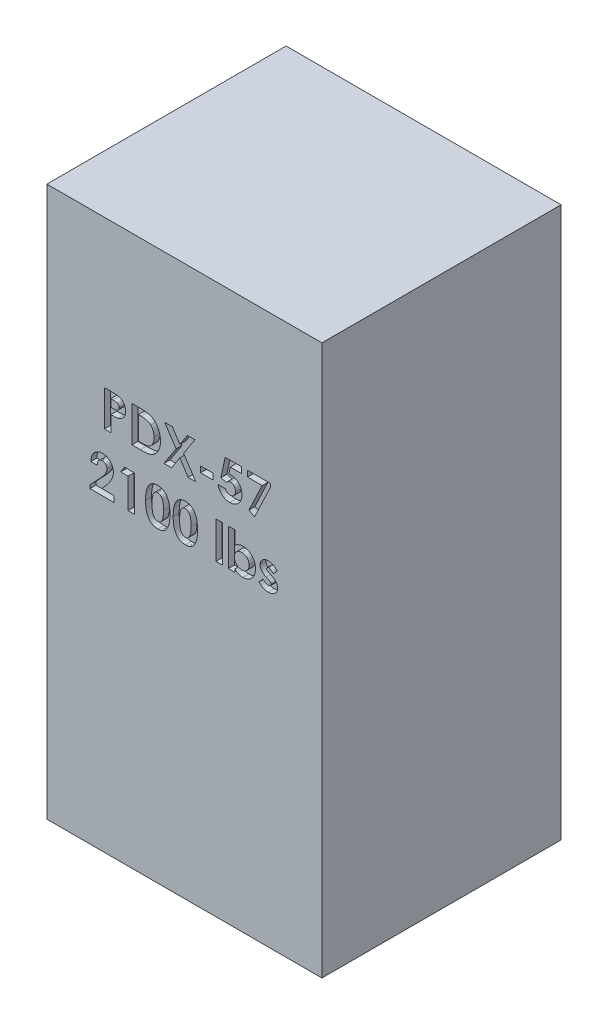
from build123d import *

# Parameters (mm, degrees)
SKETCH1_W           = 584.2
SKETCH1_H           = 1168.4
BOSS_EXTRUDE1_DEPTH = 508
SKETCH2_W           = 26.376923077
SKETCH2_H           = 12.7
SKETCH2_W_2         = 13.676923077
SKETCH2_H_2         = 78.153846154
CUT_EXTRUDE1_DEPTH  = 12.7


with BuildPart() as part:
    # Sketch1 → Boss-Extrude1 (new body)
    with BuildSketch(Plane.XY):
        Rectangle(SKETCH1_W, SKETCH1_H)
    extrude(amount=BOSS_EXTRUDE1_DEPTH)

    # Sketch2 → Cut-Extrude1 (cut)
    with BuildSketch(Plane.XY.offset(508)):
        with BuildLine():
            Line((-169.984615385, 270.933333333), (-154.720192308, 270.933333333))
            add(Edge.make_bspline(
                [(-154.720192308, 270.933333333), (-153.722834706, 270.928868948), (-151.798722834, 270.920256214), (-149.02399521, 270.815815354), (-146.464173119, 270.628650972), (-144.119844676, 270.397345395), (-141.991973811, 270.073063975), (-140.07789579, 269.701300718), (-138.377213397, 269.24838487), (-136.870748909, 268.710780037), (-135.518745693, 268.076964942), (-134.239314588, 267.401906625), (-133.06137088, 266.596248331), (-131.925460192, 265.746820491), (-130.896524496, 264.77247759), (-129.910372624, 263.738063561), (-129.008770796, 262.602554395), (-128.187541327, 261.379695125), (-127.442559656, 260.09207896), (-126.791693831, 258.737404026), (-126.263747922, 257.313526691), (-125.820866952, 255.829657822), (-125.465140642, 254.28586209), (-125.228357886, 252.672645013), (-125.067523126, 251.001270686), (-125.053331679, 249.863732265), (-125.046153846, 249.28838141)],
                knots=[0, 0, 0, 0, 0.002991983, 0.005772162, 0.008327893, 0.010691267, 0.0128371, 0.01478294, 0.016538083, 0.01811217, 0.019573813, 0.021014988, 0.022445941, 0.023850351, 0.025265339, 0.026690745, 0.028135392, 0.029608706, 0.031106332, 0.03259475, 0.034111545, 0.03565695, 0.037238126, 0.038859392, 0.040545403, 0.04227089, 0.04227089, 0.04227089, 0.04227089], degree=3))
            add(Edge.make_bspline(
                [(-125.046153846, 249.28838141), (-125.056539272, 248.651884459), (-125.07694791, 247.401089733), (-125.277018332, 245.56757812), (-125.618801825, 243.819490801), (-126.065494972, 242.142085843), (-126.688376799, 240.562960274), (-127.399990036, 239.044435675), (-128.275500034, 237.629086814), (-129.275910171, 236.299209381), (-130.368472172, 235.043990846), (-131.579123412, 233.89967327), (-132.884788357, 232.858455879), (-134.277908982, 231.909426634), (-135.763715478, 231.054499937), (-137.341135764, 230.28567031), (-139.020941359, 229.627527307), (-140.190707435, 229.283323846), (-140.783774038, 229.108814103)],
                knots=[0, 0, 0, 0, 0.00190903, 0.003751478, 0.005523729, 0.007249419, 0.00895029, 0.010609344, 0.012274356, 0.013932075, 0.015597786, 0.017260558, 0.018922138, 0.020602958, 0.022312642, 0.024060335, 0.025863153, 0.027717136, 0.027717136, 0.027717136, 0.027717136], degree=3))
            add(Edge.make_bspline(
                [(-140.783774038, 229.108814103), (-141.174401819, 229.011625278), (-142.020627382, 228.801082989), (-143.420898261, 228.58732972), (-145.034563428, 228.390796733), (-146.866840916, 228.221900422), (-148.918787079, 228.107090286), (-151.188415096, 228.017428676), (-153.676753526, 227.952235426), (-155.407045671, 227.949922083), (-156.307692308, 227.948717949)],
                knots=[0, 0, 0, 0, 0.001207048, 0.002614855, 0.004245007, 0.006084417, 0.008133492, 0.010409734, 0.012898584, 0.01560043, 0.01560043, 0.01560043, 0.01560043], degree=3))
            Line((-156.307692308, 227.948717949), (-156.307692308, 194.733333333))
            Line((-156.307692308, 194.733333333), (-169.984615385, 194.733333333))
            Line((-169.984615385, 194.733333333), (-169.984615385, 270.933333333))
        make_face()
        with BuildLine():
            Line((-156.307692308, 241.625641026), (-151.468870192, 241.625641026))
            add(Edge.make_bspline(
                [(-151.468870192, 241.625641026), (-150.588370114, 241.63122408), (-148.96823689, 241.641496982), (-146.755707028, 241.790049118), (-144.977675471, 242.016918236), (-143.572997523, 242.342301018), (-142.463871237, 242.836112476), (-141.507319254, 243.407359343), (-140.686860198, 244.129685324), (-139.976463415, 244.955066351), (-139.408522596, 245.90347052), (-139.014685219, 246.95945491), (-138.758856203, 248.100832158), (-138.735228017, 248.895155177), (-138.723076923, 249.303645833)],
                knots=[0, 0, 0, 0, 0.002641142, 0.004859741, 0.006647178, 0.008016985, 0.009165474, 0.010275482, 0.011346714, 0.01242952, 0.013531628, 0.014642895, 0.015798564, 0.017022101, 0.017022101, 0.017022101, 0.017022101], degree=3))
            add(Edge.make_bspline(
                [(-138.723076923, 249.303645833), (-138.735103026, 249.6605388), (-138.758436556, 250.352996965), (-138.929851027, 251.352385853), (-139.203036383, 252.284022461), (-139.598871463, 253.138177079), (-140.110592492, 253.913398361), (-140.734483981, 254.60938092), (-141.462540178, 255.241029812), (-142.024642129, 255.575371218), (-142.310216346, 255.745232372)],
                knots=[0, 0, 0, 0, 0.001070253, 0.002076548, 0.003032739, 0.003975186, 0.004889651, 0.005808691, 0.006772286, 0.007767405, 0.007767405, 0.007767405, 0.007767405], degree=3))
            add(Edge.make_bspline(
                [(-142.310216346, 255.745232372), (-142.552114193, 255.867567049), (-143.064261505, 256.126574631), (-143.93649803, 256.427689882), (-144.943045662, 256.681713767), (-146.090699729, 256.89255114), (-147.374881911, 257.056182836), (-148.795363089, 257.181320149), (-150.354233633, 257.231642737), (-151.438334822, 257.247926707), (-152.003125, 257.256410256)],
                knots=[0, 0, 0, 0, 0.000812463, 0.001720151, 0.002760486, 0.003925093, 0.005218251, 0.006643085, 0.008201253, 0.009895879, 0.009895879, 0.009895879, 0.009895879], degree=3))
            Line((-152.003125, 257.256410256), (-156.307692308, 257.256410256))
            Line((-156.307692308, 257.256410256), (-156.307692308, 241.625641026))
        make_face(mode=Mode.SUBTRACT)
        with BuildLine():
            Line((-111.369230769, 270.933333333), (-94.135697115, 270.933333333))
            add(Edge.make_bspline(
                [(-94.135697115, 270.933333333), (-92.792144947, 270.923941444), (-90.195043413, 270.905786816), (-86.432357086, 270.701227811), (-82.933537613, 270.386630584), (-79.696329584, 269.953845086), (-76.727369799, 269.381151356), (-74.030486674, 268.662819316), (-71.596628821, 267.833624481), (-69.399109492, 266.857908497), (-67.39298571, 265.72032056), (-65.488107152, 264.453138928), (-63.688214004, 263.009943035), (-61.968047613, 261.418575006), (-60.34980709, 259.649921251), (-58.806542931, 257.733277086), (-57.37604125, 255.640848522), (-56.015061069, 253.422805402), (-54.784235597, 251.06974787), (-53.710663628, 248.601704659), (-52.811325881, 246.034558548), (-52.080567388, 243.365573628), (-51.498068534, 240.603610115), (-51.090505824, 237.743094629), (-50.838546497, 234.786675525), (-50.812987329, 232.782965138), (-50.8, 231.764823718)],
                knots=[0, 0, 0, 0, 0.00403027, 0.007790558, 0.011300778, 0.014566972, 0.017584544, 0.020365226, 0.022933372, 0.025290725, 0.027566557, 0.029844232, 0.032147087, 0.034480098, 0.036867456, 0.039332412, 0.041855986, 0.044466024, 0.047135597, 0.049815405, 0.052533373, 0.055288591, 0.058111684, 0.060995731, 0.063951871, 0.067005709, 0.067005709, 0.067005709, 0.067005709], degree=3))
            add(Edge.make_bspline(
                [(-50.8, 231.764823718), (-50.834007839, 230.328159902), (-50.900954262, 227.500003084), (-51.464873528, 223.349715536), (-52.376921924, 219.371250977), (-53.659344807, 215.595730503), (-55.249205884, 212.056775676), (-57.148472972, 208.816794483), (-59.329298392, 205.893177501), (-61.7662754, 203.300481946), (-64.404927973, 201.072024978), (-67.147020087, 199.163514663), (-70.019264712, 197.658495028), (-72.550113634, 196.704087518), (-74.74467539, 196.110528619), (-76.67147687, 195.759729593), (-78.860126754, 195.438025731), (-81.331032299, 195.189419906), (-84.073354181, 194.967724604), (-87.098023326, 194.847264005), (-90.395246725, 194.747179129), (-92.685480131, 194.738069531), (-93.876201923, 194.733333333)],
                knots=[0, 0, 0, 0, 0.004308463, 0.008481461, 0.012539645, 0.016536476, 0.020423633, 0.024159427, 0.027780153, 0.031343669, 0.034808996, 0.038124223, 0.041346897, 0.044510906, 0.046217862, 0.048160766, 0.050382093, 0.052853328, 0.055609222, 0.058634698, 0.061933085, 0.065505091, 0.065505091, 0.065505091, 0.065505091], degree=3))
            Line((-93.876201923, 194.733333333), (-111.369230769, 194.733333333))
            Line((-111.369230769, 194.733333333), (-111.369230769, 270.933333333))
        make_face()
        with BuildLine():
            Line((-97.692307692, 257.256410256), (-97.692307692, 208.41025641))
            Line((-97.692307692, 208.41025641), (-90.548557692, 208.41025641))
            add(Edge.make_bspline(
                [(-90.548557692, 208.41025641), (-89.698561153, 208.411813956), (-88.063734843, 208.414809635), (-85.703415712, 208.557496393), (-83.520718994, 208.700714552), (-81.521653139, 208.972547407), (-79.691669571, 209.275350078), (-78.05590747, 209.696741457), (-76.580646671, 210.139377403), (-75.283907203, 210.702907824), (-74.096199506, 211.337198819), (-72.996517842, 212.080344253), (-71.93501715, 212.90557923), (-70.931543041, 213.837175085), (-69.982297607, 214.86279574), (-69.092897185, 215.987725761), (-68.251470631, 217.208532954), (-67.479615774, 218.531672029), (-66.774290674, 219.943170341), (-66.148588273, 221.429355468), (-65.629788653, 223.002604135), (-65.198594173, 224.648188836), (-64.890456823, 226.380436258), (-64.635531938, 228.186515884), (-64.504110732, 230.07358325), (-64.486073991, 231.357606954), (-64.476923077, 232.009054487)],
                knots=[0, 0, 0, 0, 0.002549341, 0.004903232, 0.007092493, 0.0091089, 0.010953433, 0.012652728, 0.014173435, 0.01556844, 0.016886583, 0.018207462, 0.019544908, 0.020916754, 0.022310171, 0.023733369, 0.025215277, 0.026754639, 0.028324724, 0.029946277, 0.031587469, 0.03329053, 0.035044943, 0.036862627, 0.038760395, 0.040714777, 0.040714777, 0.040714777, 0.040714777], degree=3))
            add(Edge.make_bspline(
                [(-64.476923077, 232.009054487), (-64.495148591, 233.007336248), (-64.530686932, 234.95390833), (-64.873410999, 237.789133058), (-65.431300403, 240.458921874), (-66.227354829, 242.953366478), (-67.230806105, 245.279477568), (-68.48685929, 247.417548055), (-69.941458691, 249.403494579), (-71.09171621, 250.568514532), (-71.666466346, 251.150641026)],
                knots=[0, 0, 0, 0, 0.002993734, 0.00583755, 0.008552945, 0.011164589, 0.013680071, 0.016135794, 0.01859033, 0.021041637, 0.021041637, 0.021041637, 0.021041637], degree=3))
            add(Edge.make_bspline(
                [(-71.666466346, 251.150641026), (-72.233224402, 251.646691495), (-73.390763555, 252.659818408), (-75.423021923, 253.873803542), (-77.66246539, 254.940408473), (-80.160325711, 255.786107234), (-82.892462174, 256.454921866), (-85.875147439, 256.916186964), (-89.092408581, 257.212591026), (-91.321252137, 257.241490917), (-92.471875, 257.256410256)],
                knots=[0, 0, 0, 0, 0.002255419, 0.004606437, 0.007071393, 0.009687806, 0.012501475, 0.015500341, 0.018734166, 0.022185141, 0.022185141, 0.022185141, 0.022185141], degree=3))
            Line((-92.471875, 257.256410256), (-97.692307692, 257.256410256))
        make_face(mode=Mode.SUBTRACT)
        Polygon((-41.778725962, 270.933333333), (-25.659495192, 270.933333333), (-9.738701923, 246.464463141), (6.212620192, 270.933333333), (22.347115385, 270.933333333), (-1.679086538, 234.085016026), (23.934615385, 194.733333333), (7.815384615, 194.733333333), (-9.738701923, 221.720833333), (-27.338581731, 194.733333333), (-43.473076923, 194.733333333), (-17.798317308, 234.100280449), align=None)
        with Locations((47.380769231, 222.575641026)):
            Rectangle(SKETCH2_W, SKETCH2_H)
        with BuildLine():
            Line((86.442427885, 270.933333333), (121.138461538, 270.933333333))
            Line((121.138461538, 270.933333333), (121.138461538, 258.233333333))
            Line((121.138461538, 258.233333333), (97.280168269, 258.233333333))
            Line((97.280168269, 258.233333333), (94.303605769, 243.823717949))
            add(Edge.make_bspline(
                [(94.303605769, 243.823717949), (94.709205019, 243.93668246), (95.509130073, 244.159471686), (96.714218159, 244.382901091), (97.882116453, 244.527720929), (98.648484188, 244.547037966), (99.0203125, 244.556410256)],
                knots=[0, 0, 0, 0, 0.001262526, 0.00248996, 0.003673322, 0.004788565, 0.004788565, 0.004788565, 0.004788565], degree=3))
            add(Edge.make_bspline(
                [(99.0203125, 244.556410256), (99.830565341, 244.537843782), (101.427752182, 244.501245172), (103.764233853, 244.153804977), (106.001553082, 243.6065972), (108.132863421, 242.826166009), (110.156082864, 241.810414658), (112.073663958, 240.58164026), (113.887960204, 239.137684639), (115.566742069, 237.477643758), (117.109276973, 235.654881284), (118.450423093, 233.683370798), (119.595845574, 231.591224124), (120.506875013, 229.365436525), (121.225937115, 227.019987439), (121.745547447, 224.553373832), (122.052818994, 221.962672402), (122.094252679, 220.195222044), (122.115384615, 219.293790064)],
                knots=[0, 0, 0, 0, 0.002429394, 0.004788871, 0.007069409, 0.009329471, 0.011582202, 0.013847568, 0.016150423, 0.018525108, 0.020919288, 0.023302934, 0.025666308, 0.028061656, 0.030504822, 0.033016596, 0.035614286, 0.0383182, 0.0383182, 0.0383182, 0.0383182], degree=3))
            add(Edge.make_bspline(
                [(122.115384615, 219.293790064), (122.08956105, 218.382124744), (122.038603606, 216.583142575), (121.706152981, 213.938002443), (121.119371657, 211.404555345), (120.313368799, 208.976019298), (119.251511625, 206.670243475), (117.974483045, 204.463341746), (116.460691952, 202.371695243), (114.724993823, 200.416745883), (112.838062273, 198.629884635), (110.828925599, 197.057979373), (108.71169859, 195.73523383), (106.48633016, 194.666231803), (104.165587952, 193.82045643), (101.748767601, 193.20477233), (99.224123667, 192.851711708), (97.510218464, 192.803826576), (96.6390625, 192.779487179)],
                knots=[0, 0, 0, 0, 0.002735059, 0.005397071, 0.007981632, 0.010525483, 0.013059653, 0.015583505, 0.018163599, 0.02079143, 0.023415357, 0.025949665, 0.028431719, 0.03088948, 0.033342545, 0.035830412, 0.038358276, 0.040971347, 0.040971347, 0.040971347, 0.040971347], degree=3))
            add(Edge.make_bspline(
                [(96.6390625, 192.779487179), (95.860013653, 192.799398321), (94.323566293, 192.838667259), (92.060446784, 193.080034839), (89.878548263, 193.506774985), (87.789454229, 194.12437847), (85.771183917, 194.88450737), (83.847069109, 195.835192209), (82.006536464, 196.958330668), (80.254812398, 198.233425443), (78.620359941, 199.669770251), (77.128604926, 201.242097119), (75.770516083, 202.930587635), (74.57515438, 204.756072637), (73.546266923, 206.715855078), (72.633828534, 208.786838469), (71.886988575, 210.990650484), (71.507988805, 212.518455415), (71.315384615, 213.294871795)],
                knots=[0, 0, 0, 0, 0.002337252, 0.00460955, 0.006818834, 0.008997373, 0.011137715, 0.013281266, 0.015425306, 0.017599134, 0.019773176, 0.021943356, 0.024093636, 0.026265533, 0.02847798, 0.03072688, 0.033048729, 0.035447916, 0.035447916, 0.035447916, 0.035447916], degree=3))
            Line((71.315384615, 213.294871795), (86.946153846, 213.294871795))
            add(Edge.make_bspline(
                [(86.946153846, 213.294871795), (87.231884685, 212.756846861), (87.787169963, 211.7112568), (88.843445323, 210.323078888), (90.025878528, 209.139300401), (91.323803389, 208.148355571), (92.745629652, 207.405956568), (94.23342058, 206.842955508), (95.805866664, 206.517618048), (96.876771874, 206.476947639), (97.417548077, 206.456410256)],
                knots=[0, 0, 0, 0, 0.001825168, 0.003547006, 0.005209217, 0.006833354, 0.008424446, 0.010003779, 0.011593406, 0.013214959, 0.013214959, 0.013214959, 0.013214959], degree=3))
            add(Edge.make_bspline(
                [(97.417548077, 206.456410256), (97.794461835, 206.470591497), (98.536046006, 206.498493328), (99.628653013, 206.646101014), (100.671594405, 206.925666625), (101.6726242, 207.312800006), (102.634431419, 207.795599059), (103.543228221, 208.405101405), (104.414826034, 209.106661205), (105.235955607, 209.91170345), (105.979662319, 210.809138294), (106.631811752, 211.773493217), (107.214923282, 212.783340036), (107.646842907, 213.878681323), (108.000548555, 215.026809798), (108.261031703, 216.236386148), (108.41669976, 217.508823057), (108.431110459, 218.377480065), (108.438461538, 218.820592949)],
                knots=[0, 0, 0, 0, 0.001131216, 0.002225687, 0.003299418, 0.004362462, 0.005441063, 0.006520637, 0.007638697, 0.008793661, 0.009964353, 0.01112866, 0.012283623, 0.013454315, 0.01465177, 0.015885264, 0.017161374, 0.018490168, 0.018490168, 0.018490168, 0.018490168], degree=3))
            add(Edge.make_bspline(
                [(108.438461538, 218.820592949), (108.429929761, 219.253420177), (108.41332245, 220.095928886), (108.275943456, 221.333033453), (108.030175082, 222.5068218), (107.695313562, 223.626284271), (107.266650841, 224.684622947), (106.742796339, 225.688137572), (106.121512101, 226.631755742), (105.39946258, 227.496266324), (104.6294764, 228.289220013), (103.802263824, 228.982730992), (102.925277599, 229.558296952), (102.025768989, 230.060782782), (101.067832851, 230.426481016), (100.073009319, 230.678323898), (99.042344582, 230.863116073), (98.339350531, 230.873973291), (97.982331731, 230.879487179)],
                knots=[0, 0, 0, 0, 0.001298284, 0.002527141, 0.003727608, 0.004891414, 0.006028076, 0.007147802, 0.008282412, 0.009410121, 0.010521912, 0.011594882, 0.012640579, 0.013665116, 0.014679942, 0.015705502, 0.016741911, 0.017811401, 0.017811401, 0.017811401, 0.017811401], degree=3))
            add(Edge.make_bspline(
                [(97.982331731, 230.879487179), (97.594526337, 230.864772119), (96.817281132, 230.83527998), (95.662489288, 230.595310334), (94.521621028, 230.20694943), (93.388331943, 229.67114401), (92.273871898, 228.969943783), (91.148829736, 228.147516308), (90.050863041, 227.144104427), (89.352745275, 226.396760979), (88.991586538, 226.010136218)],
                knots=[0, 0, 0, 0, 0.001162604, 0.002330108, 0.003522395, 0.004771935, 0.006080943, 0.007466983, 0.008947632, 0.010534618, 0.010534618, 0.010534618, 0.010534618], degree=3))
            Line((88.991586538, 226.010136218), (77.482211538, 228.65088141))
            Line((77.482211538, 228.65088141), (86.442427885, 270.933333333))
        make_face()
        Polygon((133.838461538, 270.933333333), (182.684615385, 270.933333333), (182.684615385, 263.835376603), (149.072355769, 192.779487179), (136.952403846, 198.88525641), (165.038942308, 258.233333333), (133.838461538, 258.233333333), align=None)
        with BuildLine():
            Line((-185.126923077, 120.464102564), (-198.803846154, 120.464102564))
            add(Edge.make_bspline(
                [(-198.803846154, 120.464102564), (-198.744777621, 121.498689438), (-198.629361253, 123.520210074), (-198.170264115, 126.456533525), (-197.555089706, 129.231036297), (-196.734057791, 131.834012874), (-195.702377468, 134.264517419), (-194.486596531, 136.530835655), (-193.055654538, 138.621035366), (-191.440006642, 140.525036429), (-189.667082098, 142.233133352), (-187.773688562, 143.747639391), (-185.730864027, 144.99737166), (-183.575932569, 146.025785615), (-181.309261128, 146.847440577), (-178.909403433, 147.39678341), (-176.397138751, 147.768803758), (-174.677290139, 147.801357031), (-173.800721154, 147.817948718)],
                knots=[0, 0, 0, 0, 0.003107126, 0.006071137, 0.008903994, 0.011626715, 0.014246376, 0.016814431, 0.019329358, 0.021831094, 0.024292408, 0.02670496, 0.029089974, 0.031459109, 0.033858732, 0.036306044, 0.038833908, 0.041461562, 0.041461562, 0.041461562, 0.041461562], degree=3))
            add(Edge.make_bspline(
                [(-173.800721154, 147.817948718), (-172.72474516, 147.78437543), (-170.624187868, 147.718832505), (-167.571911508, 147.159729602), (-164.721419113, 146.224543598), (-162.074782724, 144.91784212), (-159.654533622, 143.257814866), (-157.461073149, 141.278504048), (-155.560735047, 138.938382688), (-153.941470616, 136.334819415), (-152.596055401, 133.578012331), (-151.653244461, 130.727359485), (-151.033544978, 127.858505646), (-150.967450193, 125.926764679), (-150.934615385, 124.967107372)],
                knots=[0, 0, 0, 0, 0.003225998, 0.006297904, 0.009271373, 0.012199955, 0.015121328, 0.018049751, 0.021032256, 0.0241324, 0.02723198, 0.030210264, 0.033123051, 0.035998602, 0.035998602, 0.035998602, 0.035998602], degree=3))
            add(Edge.make_bspline(
                [(-150.934615385, 124.967107372), (-150.947399525, 124.386638807), (-150.973130841, 123.218298969), (-151.152044104, 121.450314042), (-151.42044935, 119.649414691), (-151.825139052, 117.817145019), (-152.329820286, 115.952991412), (-152.94207157, 114.051375099), (-153.676094675, 112.123077546), (-154.519640244, 110.146396096), (-155.525992246, 108.114913237), (-156.697749269, 105.99817625), (-158.0660124, 103.798062848), (-159.614254745, 101.502150474), (-161.349995747, 99.114060137), (-163.281708719, 96.64098551), (-165.387144866, 94.074212269), (-166.881432128, 92.3584684), (-167.649158654, 91.476963141)],
                knots=[0, 0, 0, 0, 0.001741215, 0.003504636, 0.005326674, 0.007200906, 0.00913009, 0.011118922, 0.013191345, 0.015317926, 0.017563872, 0.019989427, 0.022573446, 0.025333776, 0.028295428, 0.031428169, 0.034746839, 0.038253539, 0.038253539, 0.038253539, 0.038253539], degree=3))
            Line((-167.649158654, 91.476963141), (-175.601923077, 82.364102564))
            Line((-175.601923077, 82.364102564), (-149.957692308, 82.364102564))
            Line((-149.957692308, 82.364102564), (-149.957692308, 69.664102564))
            Line((-149.957692308, 69.664102564), (-200.757692308, 69.664102564))
            Line((-200.757692308, 69.664102564), (-200.757692308, 76.594150641))
            Line((-200.757692308, 76.594150641), (-178.196875, 100.605088141))
            add(Edge.make_bspline(
                [(-178.196875, 100.605088141), (-177.543681363, 101.305494644), (-176.278638995, 102.661974331), (-174.478614075, 104.654109064), (-172.849750527, 106.544597374), (-171.425824163, 108.353569147), (-170.132109159, 110.022348702), (-169.026292166, 111.601235136), (-168.098255825, 113.075954746), (-167.090740751, 114.85420904), (-166.133932624, 116.975093723), (-165.256003258, 119.418439841), (-164.720844556, 121.753716013), (-164.646975731, 123.275432165), (-164.611538462, 124.005448718)],
                knots=[0, 0, 0, 0, 0.00287312, 0.005564381, 0.008054494, 0.010357349, 0.012470024, 0.014388308, 0.0161374, 0.017695643, 0.020516589, 0.023104168, 0.025478411, 0.027667672, 0.027667672, 0.027667672, 0.027667672], degree=3))
            add(Edge.make_bspline(
                [(-164.611538462, 124.005448718), (-164.638034052, 124.711683413), (-164.689373505, 126.080126362), (-165.253552499, 128.026729172), (-166.127598163, 129.789179304), (-167.359251945, 131.314812759), (-168.851170425, 132.568526933), (-170.575222371, 133.501004313), (-172.517351687, 134.039039487), (-173.878821341, 134.106382269), (-174.579206731, 134.141025641)],
                knots=[0, 0, 0, 0, 0.002113172, 0.004094609, 0.006026509, 0.007981309, 0.009931813, 0.011837177, 0.013818615, 0.015917847, 0.015917847, 0.015917847, 0.015917847], degree=3))
            add(Edge.make_bspline(
                [(-174.579206731, 134.141025641), (-174.941034745, 134.128227964), (-175.653351297, 134.103033682), (-176.700400952, 133.935322162), (-177.696743924, 133.639748115), (-178.653470064, 133.243720493), (-179.56036894, 132.718783038), (-180.415153064, 132.07171399), (-181.226828668, 131.318956846), (-181.991673081, 130.462865377), (-182.687781345, 129.507467046), (-183.306062159, 128.461487464), (-183.817277464, 127.3255759), (-184.267369999, 126.114728123), (-184.614502899, 124.815938641), (-184.867258714, 123.436980563), (-185.05941208, 121.980097273), (-185.10401003, 120.978627007), (-185.126923077, 120.464102564)],
                knots=[0, 0, 0, 0, 0.001085493, 0.002136967, 0.003170673, 0.004196915, 0.005236354, 0.006304863, 0.007406655, 0.008552605, 0.009743328, 0.010947574, 0.012190664, 0.013475236, 0.014819372, 0.016217463, 0.017679107, 0.019223531, 0.019223531, 0.019223531, 0.019223531], degree=3))
        make_face()
        Polygon((-127.137379808, 145.864102564), (-105.996153846, 145.864102564), (-105.996153846, 69.664102564), (-119.673076923, 69.664102564), (-119.673076923, 133.164102564), (-135.303846154, 133.164102564), align=None)
        with BuildLine():
            add(Edge.make_bspline(
                [(-56.890504808, 147.817948718), (-56.228484964, 147.808120847), (-54.926777074, 147.788796626), (-53.009606379, 147.579499578), (-51.162840936, 147.263310109), (-49.379255968, 146.822336057), (-47.671689901, 146.238722606), (-46.027714717, 145.54014731), (-44.466898477, 144.689968454), (-42.969335787, 143.729647772), (-41.53560351, 142.642428624), (-40.200160398, 141.402942658), (-38.938618422, 140.039710499), (-37.778285322, 138.532122521), (-36.693465165, 136.893891835), (-35.68772249, 135.124758672), (-34.768756506, 133.216064307), (-33.926267797, 131.164364352), (-33.172911731, 128.938904709), (-32.538360852, 126.514158391), (-31.994127293, 123.889571667), (-31.534755769, 121.05861154), (-31.187545143, 118.01751499), (-30.953518192, 114.768302368), (-30.79291782, 111.31723768), (-30.779810738, 108.94983566), (-30.773076923, 107.733573718)],
                knots=[0, 0, 0, 0, 0.001985314, 0.003903658, 0.005778263, 0.007603431, 0.009408768, 0.011186598, 0.012955494, 0.014733849, 0.016519851, 0.01834553, 0.020192777, 0.022085812, 0.024045968, 0.026083183, 0.028185909, 0.030396933, 0.032733238, 0.035228773, 0.037911145, 0.040771952, 0.043829793, 0.047090275, 0.050543411, 0.054191895, 0.054191895, 0.054191895, 0.054191895], degree=3))
            add(Edge.make_bspline(
                [(-30.773076923, 107.733573718), (-30.780354357, 106.502094971), (-30.79449428, 104.109353857), (-30.946841988, 100.626723977), (-31.209191937, 97.353920123), (-31.547327486, 94.291280885), (-32.010480694, 91.440423595), (-32.552897483, 88.793966451), (-33.197464557, 86.352868727), (-33.975635929, 84.122630736), (-34.813025036, 82.067327547), (-35.734504786, 80.162354682), (-36.724013919, 78.402552422), (-37.758856078, 76.761371756), (-38.895765116, 75.287193856), (-40.079404464, 73.929888965), (-41.361311895, 72.741158568), (-42.687514149, 71.659740834), (-44.106595378, 70.725178893), (-45.603920973, 69.907826427), (-47.206185647, 69.2448565), (-48.884182841, 68.668240668), (-50.666514358, 68.254292717), (-52.524859194, 67.925838622), (-54.480197687, 67.744314742), (-55.811470891, 67.72179551), (-56.493629808, 67.71025641)],
                knots=[0, 0, 0, 0, 0.003694274, 0.007177909, 0.010454786, 0.013542956, 0.016418832, 0.019116147, 0.021645117, 0.023986353, 0.026197377, 0.028300103, 0.030329812, 0.03225216, 0.034114482, 0.035909464, 0.037648068, 0.039352565, 0.041037539, 0.042738204, 0.044461935, 0.046233463, 0.048054989, 0.049944636, 0.051891852, 0.053938196, 0.053938196, 0.053938196, 0.053938196], degree=3))
            add(Edge.make_bspline(
                [(-56.493629808, 67.71025641), (-57.175770312, 67.722018092), (-58.512073529, 67.745059053), (-60.472699452, 67.924488915), (-62.340892582, 68.255623291), (-64.137325205, 68.671418654), (-65.849494434, 69.24358068), (-67.485610068, 69.926386192), (-69.033091793, 70.738638786), (-70.496224343, 71.675378169), (-71.870012167, 72.7495604), (-73.175803919, 73.949695895), (-74.410711114, 75.27274262), (-75.555947749, 76.733519794), (-76.630269487, 78.312529087), (-77.622472852, 80.027802017), (-78.531961555, 81.876841188), (-79.38718457, 83.86222397), (-80.130265115, 86.026693378), (-80.791572299, 88.38957785), (-81.333297749, 90.970573974), (-81.768989604, 93.768852581), (-82.116845732, 96.778485394), (-82.375610709, 100.000925076), (-82.528804637, 103.437672562), (-82.542796274, 105.7999203), (-82.55, 107.016145833)],
                knots=[0, 0, 0, 0, 0.002046344, 0.004008757, 0.005898404, 0.007734772, 0.009535262, 0.011307119, 0.013048201, 0.014771526, 0.016511938, 0.018272913, 0.02008739, 0.021934953, 0.02383591, 0.025812579, 0.02787418, 0.030014795, 0.032293339, 0.034733976, 0.037371543, 0.04019979, 0.043227307, 0.046458537, 0.049896422, 0.053544907, 0.053544907, 0.053544907, 0.053544907], degree=3))
            add(Edge.make_bspline(
                [(-82.55, 107.016145833), (-82.536951124, 108.705995466), (-82.511773149, 111.9665821), (-82.192699357, 116.677181774), (-81.724379958, 121.031315177), (-81.036529695, 125.021698918), (-80.186012358, 128.663112214), (-79.096880622, 131.931567341), (-77.856983368, 134.872290706), (-76.800431617, 136.614392932), (-76.291586538, 137.453405449)],
                knots=[0, 0, 0, 0, 0.005068616, 0.00977996, 0.014157657, 0.018200453, 0.02192128, 0.025362958, 0.028527852, 0.031468185, 0.031468185, 0.031468185, 0.031468185], degree=3))
            add(Edge.make_bspline(
                [(-76.291586538, 137.453405449), (-75.699925718, 138.277651084), (-74.543112228, 139.889213716), (-72.520391506, 142.004894212), (-70.347241444, 143.814327773), (-67.979026779, 145.276565297), (-65.453201814, 146.429685927), (-62.748081055, 147.244122041), (-59.873654061, 147.718650471), (-57.899737096, 147.784355026), (-56.890504808, 147.817948718)],
                knots=[0, 0, 0, 0, 0.003040687, 0.005945142, 0.008753671, 0.011502709, 0.01426932, 0.017060414, 0.019953818, 0.022980834, 0.022980834, 0.022980834, 0.022980834], degree=3))
        make_face()
        with BuildLine():
            add(Edge.make_bspline(
                [(-56.5546875, 134.141025641), (-57.153158928, 134.112659285), (-58.326480614, 134.05704617), (-60.029026285, 133.584969284), (-61.634420551, 132.855821081), (-62.855601091, 131.978405221), (-63.76964258, 131.137296898), (-64.408289923, 130.376121219), (-65.024164627, 129.526704021), (-65.56813618, 128.550715471), (-66.081787322, 127.483223992), (-66.583779315, 126.319383812), (-66.995280934, 125.030608499), (-67.399570364, 123.638846062), (-67.753765628, 122.105617967), (-68.05050361, 120.418391766), (-68.315612914, 118.566195272), (-68.500529815, 116.547815294), (-68.67292786, 114.365363555), (-68.796510942, 112.013978399), (-68.848177927, 109.49429418), (-68.864601289, 107.759025051), (-68.873076923, 106.863501603)],
                knots=[0, 0, 0, 0, 0.001792449, 0.003514151, 0.005262578, 0.007058338, 0.007997937, 0.008983055, 0.010033531, 0.011141122, 0.012329004, 0.013587741, 0.014939311, 0.016383957, 0.017935382, 0.019657016, 0.021522151, 0.023546803, 0.025736064, 0.028089955, 0.030609325, 0.033296037, 0.033296037, 0.033296037, 0.033296037], degree=3))
            add(Edge.make_bspline(
                [(-68.873076923, 106.863501603), (-68.859127058, 105.703307683), (-68.832377157, 103.478549822), (-68.692273679, 100.279270551), (-68.411447884, 97.367668802), (-68.062157295, 94.72401157), (-67.571564399, 92.36544368), (-67.007105515, 90.269650894), (-66.310048984, 88.463349479), (-65.504465851, 86.920416256), (-64.612246233, 85.607846168), (-63.64370259, 84.492155682), (-62.63181036, 83.526020359), (-61.544985099, 82.741240542), (-60.385819645, 82.139821465), (-59.163990898, 81.707228151), (-57.878722403, 81.442419768), (-56.998583787, 81.405699358), (-56.5546875, 81.387179487)],
                knots=[0, 0, 0, 0, 0.003480824, 0.006674738, 0.009603161, 0.012254078, 0.014669959, 0.016825434, 0.01875866, 0.020465615, 0.022036368, 0.023508258, 0.02489051, 0.026224903, 0.027515266, 0.028794658, 0.030102865, 0.031434024, 0.031434024, 0.031434024, 0.031434024], degree=3))
            add(Edge.make_bspline(
                [(-56.5546875, 81.387179487), (-56.126024327, 81.399852159), (-55.286755135, 81.424663674), (-54.062912692, 81.679350542), (-52.905560317, 82.093416073), (-51.818192416, 82.679140836), (-50.796919626, 83.423979491), (-49.846733299, 84.331205174), (-48.97479955, 85.409860812), (-48.466806989, 86.210382824), (-48.205048077, 86.622876603)],
                knots=[0, 0, 0, 0, 0.001284481, 0.002514854, 0.003731612, 0.004960848, 0.006206559, 0.007512984, 0.008890931, 0.010355759, 0.010355759, 0.010355759, 0.010355759], degree=3))
            add(Edge.make_bspline(
                [(-48.205048077, 86.622876603), (-47.896871043, 87.186536168), (-47.250648794, 88.368484566), (-46.502839292, 90.362978416), (-45.873374933, 92.612437835), (-45.331604164, 95.123863354), (-44.961066006, 97.907160344), (-44.641958997, 100.94467968), (-44.488045757, 104.251717078), (-44.46301093, 106.542844518), (-44.45, 107.733573718)],
                knots=[0, 0, 0, 0, 0.001925255, 0.004037103, 0.006370763, 0.008930503, 0.011736833, 0.014789755, 0.018091144, 0.02166354, 0.02166354, 0.02166354, 0.02166354], degree=3))
            add(Edge.make_bspline(
                [(-44.45, 107.733573718), (-44.455025841, 108.934639022), (-44.464699728, 111.2464847), (-44.642187531, 114.56541113), (-44.889352859, 117.5966996), (-45.250884382, 120.333582473), (-45.716060398, 122.782703705), (-46.289391592, 124.943903193), (-46.965306422, 126.821440245), (-47.766860858, 128.4134427), (-48.654632199, 129.766426399), (-49.597028578, 130.927181467), (-50.59803483, 131.918204858), (-51.655976949, 132.743225968), (-52.795341373, 133.373603973), (-53.994364758, 133.818702994), (-55.255505192, 134.087972975), (-56.115781508, 134.123102727), (-56.5546875, 134.141025641)],
                knots=[0, 0, 0, 0, 0.003602695, 0.006934573, 0.009968048, 0.01272483, 0.015212556, 0.017441632, 0.019426536, 0.021187775, 0.022775422, 0.024272581, 0.025664994, 0.026993086, 0.028284442, 0.029554695, 0.030818051, 0.032133983, 0.032133983, 0.032133983, 0.032133983], degree=3))
        make_face(mode=Mode.SUBTRACT)
        with BuildLine():
            add(Edge.make_bspline(
                [(1.724879808, 147.817948718), (2.386899651, 147.808120847), (3.688607541, 147.788796626), (5.605778236, 147.579499578), (7.452543679, 147.263310109), (9.236128647, 146.822336057), (10.943694714, 146.238722606), (12.587669898, 145.54014731), (14.148486138, 144.689968454), (15.646048828, 143.729647772), (17.079781105, 142.642428624), (18.415224217, 141.402942658), (19.676766193, 140.039710499), (20.837099294, 138.532122521), (21.92191945, 136.893891835), (22.927662125, 135.124758672), (23.846628109, 133.216064307), (24.689116819, 131.164364352), (25.442472884, 128.938904709), (26.077023763, 126.514158391), (26.621257323, 123.889571667), (27.080628847, 121.05861154), (27.427839472, 118.01751499), (27.661866423, 114.768302368), (27.822466795, 111.31723768), (27.835573878, 108.94983566), (27.842307692, 107.733573718)],
                knots=[0, 0, 0, 0, 0.001985314, 0.003903658, 0.005778263, 0.007603431, 0.009408768, 0.011186598, 0.012955494, 0.014733849, 0.016519851, 0.01834553, 0.020192777, 0.022085812, 0.024045968, 0.026083183, 0.028185909, 0.030396933, 0.032733238, 0.035228773, 0.037911145, 0.040771952, 0.043829793, 0.047090275, 0.050543411, 0.054191895, 0.054191895, 0.054191895, 0.054191895], degree=3))
            add(Edge.make_bspline(
                [(27.842307692, 107.733573718), (27.835030258, 106.502094971), (27.820890335, 104.109353857), (27.668542628, 100.626723977), (27.406192678, 97.353920123), (27.06805713, 94.291280885), (26.604903921, 91.440423595), (26.062487132, 88.793966451), (25.417920059, 86.352868727), (24.639748687, 84.122630736), (23.80235958, 82.067327547), (22.880879829, 80.162354682), (21.891370696, 78.402552422), (20.856528537, 76.761371756), (19.7196195, 75.287193856), (18.535980151, 73.929888965), (17.254072721, 72.741158568), (15.927870467, 71.659740834), (14.508789237, 70.725178893), (13.011463643, 69.907826427), (11.409198969, 69.2448565), (9.731201774, 68.668240668), (7.948870258, 68.254292717), (6.090525422, 67.925838622), (4.135186928, 67.744314742), (2.803913725, 67.72179551), (2.121754808, 67.71025641)],
                knots=[0, 0, 0, 0, 0.003694274, 0.007177909, 0.010454786, 0.013542956, 0.016418832, 0.019116147, 0.021645117, 0.023986353, 0.026197377, 0.028300103, 0.030329812, 0.03225216, 0.034114482, 0.035909464, 0.037648068, 0.039352565, 0.041037539, 0.042738204, 0.044461935, 0.046233463, 0.048054989, 0.049944636, 0.051891852, 0.053938196, 0.053938196, 0.053938196, 0.053938196], degree=3))
            add(Edge.make_bspline(
                [(2.121754808, 67.71025641), (1.439614303, 67.722018092), (0.103311086, 67.745059053), (-1.857314837, 67.924488915), (-3.725507967, 68.255623291), (-5.52194059, 68.671418654), (-7.234109819, 69.24358068), (-8.870225453, 69.926386192), (-10.417707178, 70.738638786), (-11.880839728, 71.675378169), (-13.254627551, 72.7495604), (-14.560419304, 73.949695895), (-15.795326498, 75.27274262), (-16.940563134, 76.733519794), (-18.014884872, 78.312529087), (-19.007088236, 80.027802017), (-19.916576939, 81.876841188), (-20.771799954, 83.86222397), (-21.5148805, 86.026693378), (-22.176187683, 88.38957785), (-22.717913133, 90.970573974), (-23.153604989, 93.768852581), (-23.501461117, 96.778485394), (-23.760226093, 100.000925076), (-23.913420022, 103.437672562), (-23.927411659, 105.7999203), (-23.934615385, 107.016145833)],
                knots=[0, 0, 0, 0, 0.002046344, 0.004008757, 0.005898404, 0.007734772, 0.009535262, 0.011307119, 0.013048201, 0.014771526, 0.016511938, 0.018272913, 0.02008739, 0.021934953, 0.02383591, 0.025812579, 0.02787418, 0.030014795, 0.032293339, 0.034733976, 0.037371543, 0.04019979, 0.043227307, 0.046458537, 0.049896422, 0.053544907, 0.053544907, 0.053544907, 0.053544907], degree=3))
            add(Edge.make_bspline(
                [(-23.934615385, 107.016145833), (-23.921566508, 108.705995466), (-23.896388533, 111.9665821), (-23.577314742, 116.677181774), (-23.108995342, 121.031315177), (-22.42114508, 125.021698918), (-21.570627743, 128.663112214), (-20.481496007, 131.931567341), (-19.241598753, 134.872290706), (-18.185047002, 136.614392932), (-17.676201923, 137.453405449)],
                knots=[0, 0, 0, 0, 0.005068616, 0.00977996, 0.014157657, 0.018200453, 0.02192128, 0.025362958, 0.028527852, 0.031468185, 0.031468185, 0.031468185, 0.031468185], degree=3))
            add(Edge.make_bspline(
                [(-17.676201923, 137.453405449), (-17.084541103, 138.277651084), (-15.927727613, 139.889213716), (-13.90500689, 142.004894212), (-11.731856829, 143.814327773), (-9.363642164, 145.276565297), (-6.837817198, 146.429685927), (-4.13269644, 147.244122041), (-1.258269445, 147.718650471), (0.715647519, 147.784355026), (1.724879808, 147.817948718)],
                knots=[0, 0, 0, 0, 0.003040687, 0.005945142, 0.008753671, 0.011502709, 0.01426932, 0.017060414, 0.019953818, 0.022980834, 0.022980834, 0.022980834, 0.022980834], degree=3))
        make_face()
        with BuildLine():
            add(Edge.make_bspline(
                [(2.060697115, 134.141025641), (1.462225688, 134.112659285), (0.288904001, 134.05704617), (-1.41364167, 133.584969284), (-3.019035936, 132.855821081), (-4.240216476, 131.978405221), (-5.154257965, 131.137296898), (-5.792905307, 130.376121219), (-6.408780011, 129.526704021), (-6.952751565, 128.550715471), (-7.466402707, 127.483223992), (-7.9683947, 126.319383812), (-8.379896318, 125.030608499), (-8.784185748, 123.638846062), (-9.138381013, 122.105617967), (-9.435118995, 120.418391766), (-9.700228299, 118.566195272), (-9.8851452, 116.547815294), (-10.057543244, 114.365363555), (-10.181126327, 112.013978399), (-10.232793311, 109.49429418), (-10.249216674, 107.759025051), (-10.257692308, 106.863501603)],
                knots=[0, 0, 0, 0, 0.001792449, 0.003514151, 0.005262578, 0.007058338, 0.007997937, 0.008983055, 0.010033531, 0.011141122, 0.012329004, 0.013587741, 0.014939311, 0.016383957, 0.017935382, 0.019657016, 0.021522151, 0.023546803, 0.025736064, 0.028089955, 0.030609325, 0.033296037, 0.033296037, 0.033296037, 0.033296037], degree=3))
            add(Edge.make_bspline(
                [(-10.257692308, 106.863501603), (-10.243742443, 105.703307683), (-10.216992542, 103.478549822), (-10.076889063, 100.279270551), (-9.796063268, 97.367668802), (-9.446772679, 94.72401157), (-8.956179784, 92.36544368), (-8.3917209, 90.269650894), (-7.694664369, 88.463349479), (-6.889081236, 86.920416256), (-5.996861618, 85.607846168), (-5.028317974, 84.492155682), (-4.016425745, 83.526020359), (-2.929600484, 82.741240542), (-1.77043503, 82.139821465), (-0.548606283, 81.707228151), (0.736662213, 81.442419768), (1.616800828, 81.405699358), (2.060697115, 81.387179487)],
                knots=[0, 0, 0, 0, 0.003480824, 0.006674738, 0.009603161, 0.012254078, 0.014669959, 0.016825434, 0.01875866, 0.020465615, 0.022036368, 0.023508258, 0.02489051, 0.026224903, 0.027515266, 0.028794658, 0.030102865, 0.031434024, 0.031434024, 0.031434024, 0.031434024], degree=3))
            add(Edge.make_bspline(
                [(2.060697115, 81.387179487), (2.489360289, 81.399852159), (3.32862948, 81.424663674), (4.552471923, 81.679350542), (5.709824299, 82.093416073), (6.797192199, 82.679140836), (7.81846499, 83.423979491), (8.768651317, 84.331205174), (9.640585066, 85.409860812), (10.148577626, 86.210382824), (10.410336538, 86.622876603)],
                knots=[0, 0, 0, 0, 0.001284481, 0.002514854, 0.003731612, 0.004960848, 0.006206559, 0.007512984, 0.008890931, 0.010355759, 0.010355759, 0.010355759, 0.010355759], degree=3))
            add(Edge.make_bspline(
                [(10.410336538, 86.622876603), (10.718513573, 87.186536168), (11.364735821, 88.368484566), (12.112545323, 90.362978416), (12.742009682, 92.612437835), (13.283780452, 95.123863354), (13.654318609, 97.907160344), (13.973425618, 100.94467968), (14.127338858, 104.251717078), (14.152373685, 106.542844518), (14.165384615, 107.733573718)],
                knots=[0, 0, 0, 0, 0.001925255, 0.004037103, 0.006370763, 0.008930503, 0.011736833, 0.014789755, 0.018091144, 0.02166354, 0.02166354, 0.02166354, 0.02166354], degree=3))
            add(Edge.make_bspline(
                [(14.165384615, 107.733573718), (14.160358774, 108.934639022), (14.150684888, 111.2464847), (13.973197084, 114.56541113), (13.726031756, 117.5966996), (13.364500233, 120.333582473), (12.899324218, 122.782703705), (12.325993023, 124.943903193), (11.650078193, 126.821440245), (10.848523757, 128.4134427), (9.960752416, 129.766426399), (9.018356037, 130.927181467), (8.017349785, 131.918204858), (6.959407666, 132.743225968), (5.820043242, 133.373603973), (4.621019858, 133.818702994), (3.359879424, 134.087972975), (2.499603108, 134.123102727), (2.060697115, 134.141025641)],
                knots=[0, 0, 0, 0, 0.003602695, 0.006934573, 0.009968048, 0.01272483, 0.015212556, 0.017441632, 0.019426536, 0.021187775, 0.022775422, 0.024272581, 0.025664994, 0.026993086, 0.028284442, 0.029554695, 0.030818051, 0.032133983, 0.032133983, 0.032133983, 0.032133983], degree=3))
        make_face(mode=Mode.SUBTRACT)
        with Locations((73.757692308, 108.741025641)):
            Rectangle(SKETCH2_W_2, SKETCH2_H_2)
        with BuildLine():
            Line((106.973076923, 147.817948718), (106.973076923, 118.861338141))
            add(Edge.make_bspline(
                [(106.973076923, 118.861338141), (107.608170679, 119.459317191), (108.854893539, 120.633181907), (110.890442045, 122.151117465), (112.999027845, 123.432242636), (115.178761966, 124.507046721), (117.449262213, 125.301817997), (119.782631378, 125.919385054), (122.202778832, 126.246461586), (123.839422282, 126.299102086), (124.664543269, 126.325641026)],
                knots=[0, 0, 0, 0, 0.002615255, 0.005133885, 0.007599928, 0.010009822, 0.012409446, 0.014804793, 0.017239839, 0.019715689, 0.019715689, 0.019715689, 0.019715689], degree=3))
            add(Edge.make_bspline(
                [(124.664543269, 126.325641026), (125.561460968, 126.304157585), (127.328097805, 126.261842179), (129.92736777, 125.866767075), (132.4182987, 125.228155354), (134.81038916, 124.336479338), (137.090894365, 123.17878695), (139.285437418, 121.792668902), (141.35617084, 120.120926359), (143.304101283, 118.227397622), (145.105985468, 116.151949468), (146.673292869, 113.895496836), (147.978799109, 111.487738977), (149.08527979, 108.957140613), (149.892833837, 106.261732615), (150.515229114, 103.437672076), (150.862062691, 100.461066835), (150.910117676, 98.43328962), (150.934615385, 97.399559295)],
                knots=[0, 0, 0, 0, 0.002689312, 0.005297073, 0.007866443, 0.010392647, 0.012938925, 0.015526234, 0.018165213, 0.020907122, 0.023667114, 0.026398251, 0.029130754, 0.031872662, 0.034668219, 0.037557392, 0.040539429, 0.043640512, 0.043640512, 0.043640512, 0.043640512], degree=3))
            add(Edge.make_bspline(
                [(150.934615385, 97.399559295), (150.911429936, 96.401216313), (150.865726304, 94.433262176), (150.496469778, 91.544143564), (149.870610885, 88.784216276), (148.992657695, 86.15248635), (147.876542658, 83.640637062), (146.514247215, 81.250399218), (144.897824811, 78.990121859), (143.049836871, 76.89025321), (141.0306415, 74.988666046), (138.926784655, 73.282564288), (136.696364427, 71.884547688), (134.395136338, 70.703815564), (131.986847321, 69.800932559), (129.487947048, 69.168361534), (126.902393169, 68.745448562), (125.144531451, 68.706795962), (124.252403846, 68.687179487)],
                knots=[0, 0, 0, 0, 0.002994318, 0.005902461, 0.008720432, 0.011471842, 0.014212008, 0.016953534, 0.019711034, 0.022534127, 0.025330684, 0.028024498, 0.03064576, 0.033212545, 0.035772694, 0.038342064, 0.040937016, 0.04361108, 0.04361108, 0.04361108, 0.04361108], degree=3))
            add(Edge.make_bspline(
                [(124.252403846, 68.687179487), (123.457718774, 68.708423518), (121.89292609, 68.750254558), (119.586356547, 69.060505735), (117.369826962, 69.582288435), (115.215337294, 70.301047473), (113.117041711, 71.283083642), (111.038398357, 72.510991405), (108.966029527, 74.000306624), (107.650766972, 75.147995412), (106.973076923, 75.739342949)],
                knots=[0, 0, 0, 0, 0.002383646, 0.004693572, 0.006966947, 0.009206712, 0.011494593, 0.013903085, 0.016440563, 0.019137705, 0.019137705, 0.019137705, 0.019137705], degree=3))
            Line((106.973076923, 75.739342949), (106.973076923, 69.664102564))
            Line((106.973076923, 69.664102564), (93.296153846, 69.664102564))
            Line((93.296153846, 69.664102564), (93.296153846, 147.817948718))
            Line((93.296153846, 147.817948718), (106.973076923, 147.817948718))
        make_face()
        with BuildLine():
            add(Edge.make_bspline(
                [(121.703245192, 113.625641026), (121.148194851, 113.608572846), (120.059994446, 113.575109935), (118.462318056, 113.383334142), (116.948491544, 113.022506587), (115.49549841, 112.554837128), (114.121737723, 111.923556815), (112.815970562, 111.158315304), (111.589380954, 110.24582322), (110.435602921, 109.222214119), (109.39884163, 108.070651957), (108.477769159, 106.84014806), (107.71361685, 105.514678947), (107.076612615, 104.111051413), (106.59602075, 102.614078348), (106.239560822, 101.036494531), (106.045847446, 99.373465366), (106.012980366, 98.239563205), (105.996153846, 97.659054487)],
                knots=[0, 0, 0, 0, 0.001665572, 0.003265426, 0.00481685, 0.00632772, 0.007837355, 0.009342662, 0.010859995, 0.012416667, 0.013961997, 0.015500678, 0.017019162, 0.018542701, 0.020116344, 0.021727301, 0.023387759, 0.025129576, 0.025129576, 0.025129576, 0.025129576], degree=3))
            add(Edge.make_bspline(
                [(105.996153846, 97.659054487), (106.013192094, 97.068386392), (106.046630388, 95.909174824), (106.238728915, 94.210683791), (106.592686856, 92.601493682), (107.083400891, 91.077956051), (107.709565642, 89.63987323), (108.472812577, 88.281914037), (109.404023671, 87.033851024), (110.429395755, 85.851927136), (111.590307883, 84.814621927), (112.811371679, 83.884301847), (114.121420489, 83.117919656), (115.501746427, 82.49696893), (116.941875699, 81.980962277), (118.46326898, 81.632297115), (120.05974212, 81.43696475), (121.148109621, 81.403995744), (121.703245192, 81.387179487)],
                knots=[0, 0, 0, 0, 0.001772317, 0.003478249, 0.005119015, 0.006707175, 0.008272578, 0.009817531, 0.011368505, 0.012936585, 0.014503477, 0.016029919, 0.017535226, 0.019044862, 0.020565569, 0.022116993, 0.023716847, 0.025382419, 0.025382419, 0.025382419, 0.025382419], degree=3))
            add(Edge.make_bspline(
                [(121.703245192, 81.387179487), (122.238187879, 81.402801277), (123.29706754, 81.433723461), (124.846387872, 81.649487591), (126.3356707, 82.002067631), (127.753252976, 82.504621731), (129.107764077, 83.158946656), (130.41153508, 83.92461512), (131.61955491, 84.881260702), (132.779216198, 85.932695865), (133.816803237, 87.118412332), (134.747643508, 88.378079908), (135.529576999, 89.722941384), (136.150413762, 91.157456518), (136.663677214, 92.654453511), (137.014098365, 94.241332582), (137.20689366, 95.903929703), (137.240591198, 97.03782335), (137.257692308, 97.613261218)],
                knots=[0, 0, 0, 0, 0.001604581, 0.003176149, 0.004683004, 0.006189317, 0.007677735, 0.009190839, 0.010714378, 0.012291571, 0.013881198, 0.015432171, 0.016984721, 0.018536145, 0.020114593, 0.02172555, 0.023401164, 0.025127732, 0.025127732, 0.025127732, 0.025127732], degree=3))
            add(Edge.make_bspline(
                [(137.257692308, 97.613261218), (137.240318101, 98.183522084), (137.206086049, 99.30709565), (137.017238792, 100.955847788), (136.653325895, 102.519656367), (136.193839539, 104.011296567), (135.551895913, 105.411351108), (134.7928623, 106.736382421), (133.899718627, 107.990391341), (132.863633486, 109.139525759), (131.727230698, 110.185155526), (130.514140074, 111.110023678), (129.229125538, 111.897349991), (127.854687997, 112.518245967), (126.423262017, 113.029109546), (124.912972423, 113.38099913), (123.331497376, 113.575754514), (122.253285538, 113.608788849), (121.703245192, 113.625641026)],
                knots=[0, 0, 0, 0, 0.001711318, 0.003371776, 0.004967839, 0.006522264, 0.008045803, 0.009577503, 0.01109821, 0.012654882, 0.014210506, 0.015724764, 0.0172248, 0.018720557, 0.020241265, 0.021777824, 0.023362533, 0.025012857, 0.025012857, 0.025012857, 0.025012857], degree=3))
        make_face(mode=Mode.SUBTRACT)
        with BuildLine():
            Line((196.85, 116.754847756), (188.485096154, 107.764102564))
            add(Edge.make_bspline(
                [(188.485096154, 107.764102564), (188.067396431, 108.226309954), (187.268495089, 109.110337603), (186.045454349, 110.315464866), (184.840627067, 111.318979879), (183.676465111, 112.161974312), (182.529192138, 112.808450273), (181.408344562, 113.273575247), (180.313384602, 113.568843498), (179.587598851, 113.607064856), (179.234855769, 113.625641026)],
                knots=[0, 0, 0, 0, 0.001868817, 0.003574339, 0.005145685, 0.006568801, 0.00788092, 0.009085649, 0.010203709, 0.011260929, 0.011260929, 0.011260929, 0.011260929], degree=3))
            add(Edge.make_bspline(
                [(179.234855769, 113.625641026), (178.877915202, 113.6147627), (178.194485053, 113.593934089), (177.23001197, 113.41527686), (176.382657843, 113.105988265), (175.665646178, 112.684399089), (175.089586314, 112.165044522), (174.68625994, 111.57091515), (174.415422571, 110.920489797), (174.392511483, 110.458467539), (174.380769231, 110.221674679)],
                knots=[0, 0, 0, 0, 0.001070253, 0.002049201, 0.002928199, 0.003763289, 0.004530317, 0.005233144, 0.005904952, 0.006611251, 0.006611251, 0.006611251, 0.006611251], degree=3))
            add(Edge.make_bspline(
                [(174.380769231, 110.221674679), (174.420553059, 109.862831154), (174.50309988, 109.118272524), (175.070082067, 108.254695596), (175.820240444, 107.617652577), (176.684956147, 107.024847467), (177.856005066, 106.362027882), (178.744392501, 105.908175947), (179.234855769, 105.657612179)],
                knots=[0, 0, 0, 0, 0.001071776, 0.00222381, 0.002980593, 0.004022271, 0.005362762, 0.00701499, 0.00701499, 0.00701499, 0.00701499], degree=3))
            Line((179.234855769, 105.657612179), (184.180528846, 103.154246795))
            add(Edge.make_bspline(
                [(184.180528846, 103.154246795), (184.809713024, 102.834767508), (186.030448519, 102.214917677), (187.746688265, 101.21470674), (189.331834657, 100.24523047), (190.754090119, 99.251648243), (192.022159771, 98.251221903), (193.127036575, 97.234058556), (194.095519359, 96.232404202), (195.175513608, 94.889459553), (196.255831993, 93.100766549), (197.156482001, 90.774654647), (197.730815561, 88.283900256), (197.794358953, 86.559954165), (197.826923077, 85.676482372)],
                knots=[0, 0, 0, 0, 0.002116477, 0.004106363, 0.005957391, 0.007689348, 0.009308025, 0.010798945, 0.012191693, 0.013483771, 0.015962865, 0.01842328, 0.02094154, 0.02358863, 0.02358863, 0.02358863, 0.02358863], degree=3))
            add(Edge.make_bspline(
                [(197.826923077, 85.676482372), (197.807302983, 85.080454734), (197.768901253, 83.913870471), (197.526133616, 82.196769655), (197.090060072, 80.564061015), (196.516187948, 78.990293877), (195.743199395, 77.503926751), (194.804753415, 76.097754245), (193.715668422, 74.753314082), (192.447152882, 73.516596919), (191.057515324, 72.36399006), (189.512698669, 71.394564923), (187.881007989, 70.542217416), (186.119336602, 69.876609905), (184.252402948, 69.336979059), (182.264203552, 68.963028404), (180.161484786, 68.727691674), (178.721606514, 68.700912854), (177.983173077, 68.687179487)],
                knots=[0, 0, 0, 0, 0.001788284, 0.003500147, 0.005188436, 0.006849946, 0.008515728, 0.010200702, 0.011914809, 0.013695782, 0.015507624, 0.017319917, 0.019156348, 0.021021608, 0.022958988, 0.024979723, 0.027083446, 0.029298103, 0.029298103, 0.029298103, 0.029298103], degree=3))
            add(Edge.make_bspline(
                [(177.983173077, 68.687179487), (177.004812191, 68.718334845), (175.08437591, 68.77949007), (172.279717754, 69.205488637), (169.631375875, 69.94289933), (167.137171413, 70.975917384), (164.781827722, 72.292265574), (162.598981749, 73.925565523), (160.55079187, 75.833262879), (159.359133719, 77.296377909), (158.75, 78.044270833)],
                knots=[0, 0, 0, 0, 0.002934742, 0.005760639, 0.00848644, 0.01116242, 0.013841533, 0.016558643, 0.019323147, 0.022213933, 0.022213933, 0.022213933, 0.022213933], degree=3))
            Line((158.75, 78.044270833), (167.038581731, 87.248717949))
            add(Edge.make_bspline(
                [(167.038581731, 87.248717949), (167.442429423, 86.822762486), (168.244199172, 85.977101582), (169.595658975, 84.861983344), (171.025599161, 83.845635109), (172.549938383, 82.992234205), (174.074585617, 82.303151375), (175.537358847, 81.786242858), (176.910690488, 81.461400757), (177.803595317, 81.411068974), (178.227403846, 81.387179487)],
                knots=[0, 0, 0, 0, 0.001759386, 0.003492957, 0.005246174, 0.007016452, 0.008724432, 0.01025955, 0.01166686, 0.012938305, 0.012938305, 0.012938305, 0.012938305], degree=3))
            add(Edge.make_bspline(
                [(178.227403846, 81.387179487), (178.650982973, 81.399446622), (179.465218959, 81.423027441), (180.622459128, 81.668314242), (181.648174417, 82.08067759), (182.518019171, 82.652429834), (183.241532762, 83.308714093), (183.751327094, 84.054585001), (184.088430096, 84.845492055), (184.129401018, 85.398464165), (184.15, 85.676482372)],
                knots=[0, 0, 0, 0, 0.001269244, 0.002439837, 0.003528331, 0.004565638, 0.005548387, 0.006437531, 0.007259546, 0.008090721, 0.008090721, 0.008090721, 0.008090721], degree=3))
            add(Edge.make_bspline(
                [(184.15, 85.676482372), (184.1316196, 85.938295044), (184.093881095, 86.475846931), (183.795104139, 87.269311977), (183.326018437, 88.054969686), (182.675422164, 88.835035186), (181.834658305, 89.60317917), (180.806735746, 90.35324906), (179.615368689, 91.125262003), (178.735357169, 91.58605035), (178.273197115, 91.828044872)],
                knots=[0, 0, 0, 0, 0.000783855, 0.001609404, 0.002512589, 0.003521081, 0.004644443, 0.005920552, 0.007334799, 0.008899012, 0.008899012, 0.008899012, 0.008899012], degree=3))
            Line((178.273197115, 91.828044872), (173.739663462, 94.117708333))
            add(Edge.make_bspline(
                [(173.739663462, 94.117708333), (172.711277051, 94.669170267), (170.737160721, 95.727770418), (168.068893408, 97.543044707), (165.810590335, 99.475440318), (163.960411166, 101.514575756), (162.486184742, 103.654728719), (161.457812902, 105.923147541), (160.810873083, 108.2983271), (160.739699351, 109.922500651), (160.703846154, 110.740665064)],
                knots=[0, 0, 0, 0, 0.003498984, 0.006716737, 0.009660516, 0.012394894, 0.014956271, 0.01742222, 0.019836171, 0.022286527, 0.022286527, 0.022286527, 0.022286527], degree=3))
            add(Edge.make_bspline(
                [(160.703846154, 110.740665064), (160.716279744, 111.270922338), (160.740688901, 112.311903518), (161.000539045, 113.840656522), (161.39311685, 115.310176795), (161.947086423, 116.722798067), (162.656711774, 118.079922031), (163.526125941, 119.375525889), (164.565935697, 120.607254216), (165.742852352, 121.771139347), (167.048678324, 122.831139647), (168.446104165, 123.770547784), (169.930996554, 124.570748834), (171.515541802, 125.208726033), (173.179599487, 125.716516177), (174.934154154, 126.061675696), (176.771720072, 126.281198357), (178.028322099, 126.310616898), (178.670072115, 126.325641026)],
                knots=[0, 0, 0, 0, 0.001589334, 0.00312012, 0.004638297, 0.006146311, 0.007662031, 0.009224231, 0.010817079, 0.012490118, 0.014182749, 0.015855022, 0.017535011, 0.019232933, 0.020971336, 0.022746543, 0.024590698, 0.026515529, 0.026515529, 0.026515529, 0.026515529], degree=3))
            add(Edge.make_bspline(
                [(178.670072115, 126.325641026), (179.557295658, 126.296429967), (181.318277889, 126.238451168), (183.915380338, 125.769286375), (186.423911913, 124.980728649), (188.836840027, 123.894227973), (191.123126894, 122.528805402), (193.232495955, 120.870721248), (195.179222691, 118.960805059), (196.287543843, 117.497468727), (196.85, 116.754847756)],
                knots=[0, 0, 0, 0, 0.002660392, 0.005280409, 0.007887455, 0.010531551, 0.013201734, 0.015855199, 0.018564408, 0.021355962, 0.021355962, 0.021355962, 0.021355962], degree=3))
        make_face()
    extrude(amount=-CUT_EXTRUDE1_DEPTH, mode=Mode.SUBTRACT)


solid = part.part
